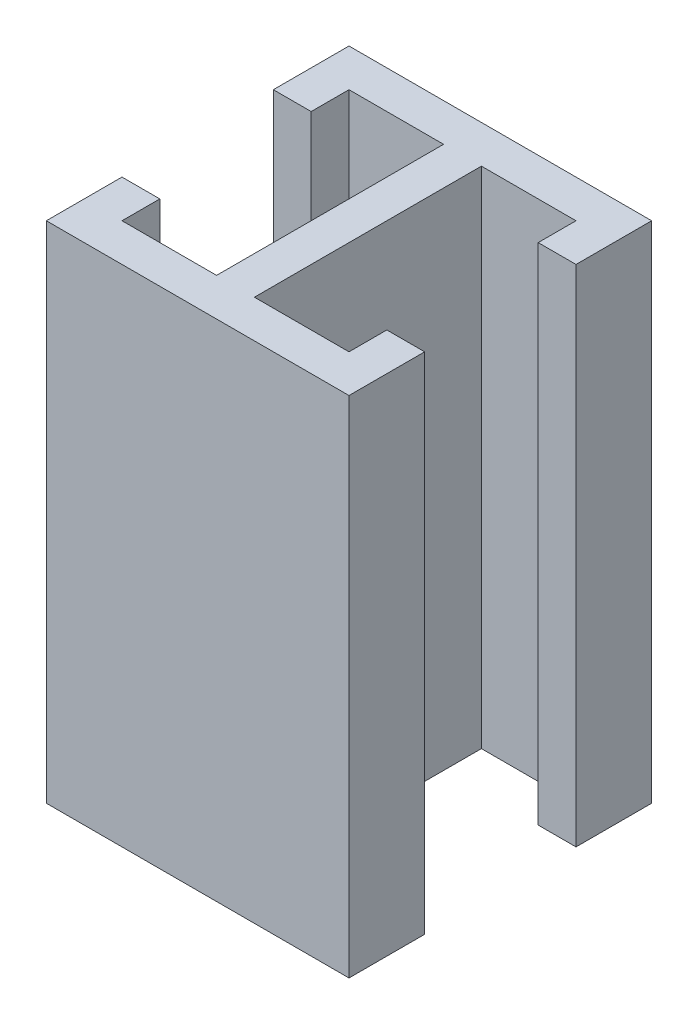
from build123d import *

# Parameters (mm, degrees)
EXTRUDE_1_DEPTH = 200


with BuildPart() as part:
    # ｽｹｯﾁ5 → ﾎﾞｽ - 押し出し1 (new body)
    with BuildSketch(Plane(origin=(0, 0, 0), x_dir=(1, 0, 0), z_dir=(0, 1, 0))):
        Polygon((0, 0), (120, 0), (120, 30), (105, 30), (105, 15), (67.5, 15), (67.5, 105), (105, 105), (105, 90), (120, 90), (120, 120), (0, 120), (0, 90), (15, 90), (15, 105), (52.5, 105), (52.5, 15), (15, 15), (15, 30), (0, 30), align=None)
    extrude(amount=EXTRUDE_1_DEPTH)


solid = part.part
